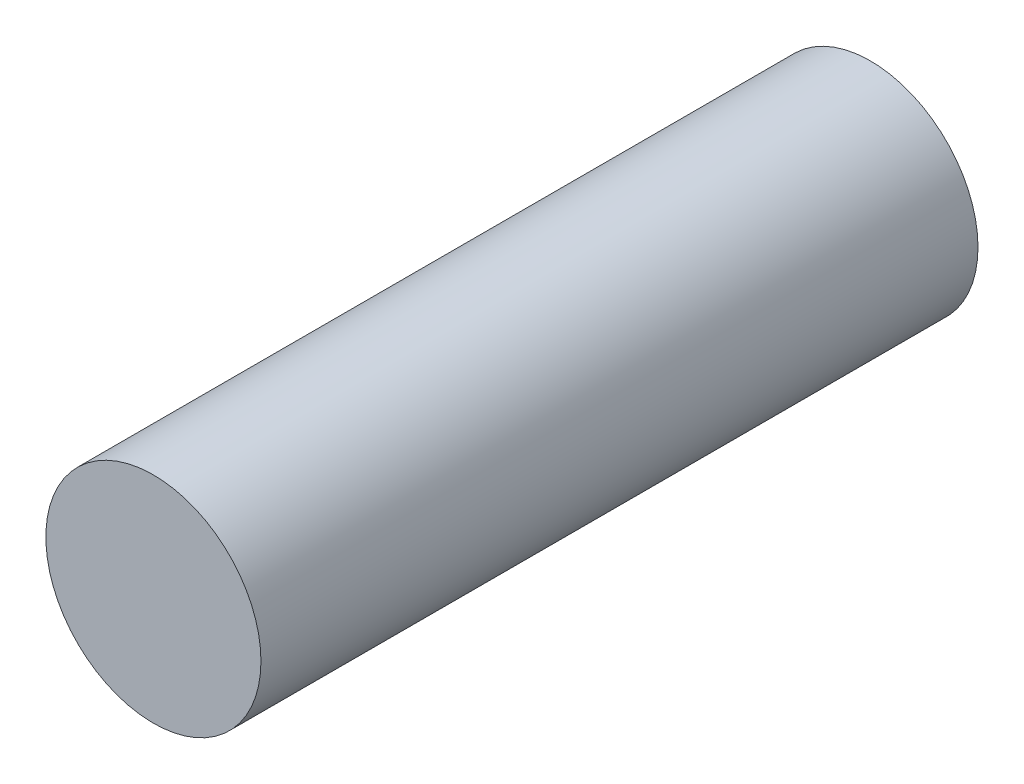
from build123d import *

# Parameters (mm, degrees)
SKETCH1_R      = 6
EXTRUDE1_DEPTH = 20


with BuildPart() as part:
    # Sketch1 → Extrude1 (new body, symmetric)
    with BuildSketch(Plane.XY):
        Circle(SKETCH1_R)
    extrude(amount=EXTRUDE1_DEPTH, both=True)


solid = part.part
